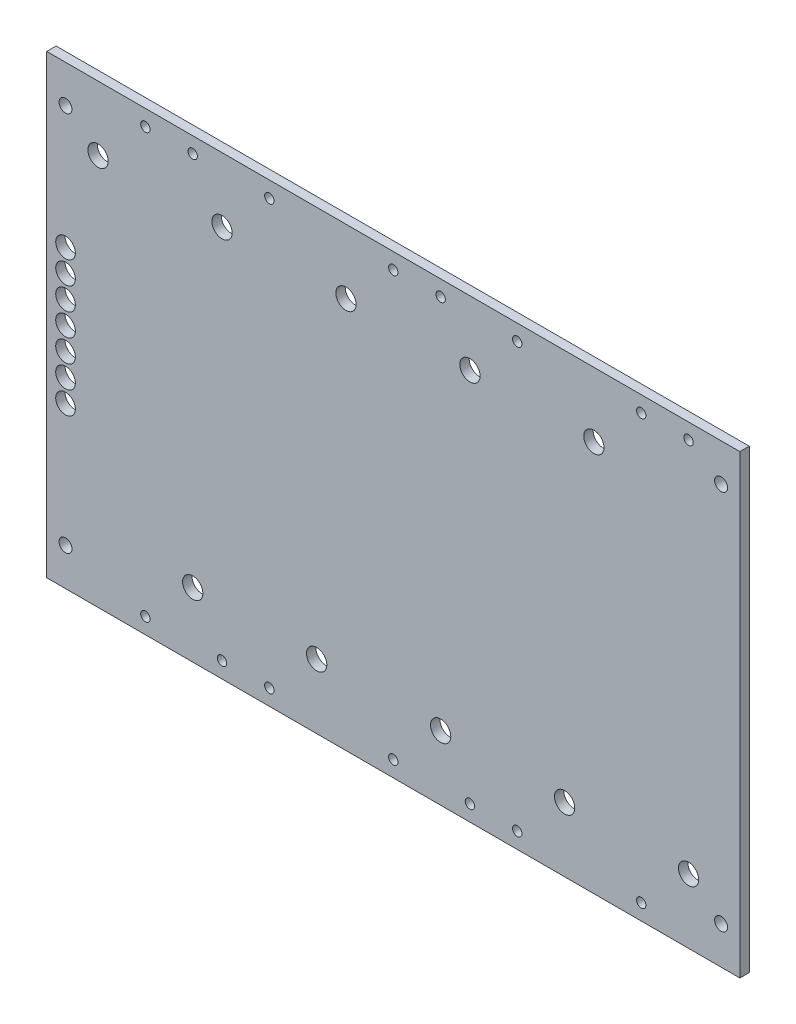
from build123d import *

# Parameters (mm, degrees)
SKETCH1_W           = 117.1702
SKETCH1_H           = 77.0636
SKETCH1_R           = 1.0922
SKETCH1_R_2         = 0.79375
SKETCH1_R_3         = 1.7145
SKETCH1_R_4         = 1.659299133
BOSS_EXTRUDE1_DEPTH = 1.5875


with BuildPart() as part:
    # Sketch1 → Boss-Extrude1 (new body)
    with BuildSketch(Plane.XY):
        with Locations((52.2351, 38.5318)):
            Rectangle(SKETCH1_W, SKETCH1_H)
        with Locations((-3.175, 6.35)):
            Circle(SKETCH1_R, mode=Mode.SUBTRACT)
        with Locations((10.3251, 2.6924)):
            Circle(SKETCH1_R_2, mode=Mode.SUBTRACT)
        with Locations((23.2791, 2.6924)):
            Circle(SKETCH1_R_2, mode=Mode.SUBTRACT)
        with Locations((18.3261, 10.9093)):
            Circle(SKETCH1_R_3, mode=Mode.SUBTRACT)
        with Locations((31.2801, 2.6924)):
            Circle(SKETCH1_R_2, mode=Mode.SUBTRACT)
        with Locations((52.2351, 2.6924)):
            Circle(SKETCH1_R_2, mode=Mode.SUBTRACT)
        with Locations((39.2811, 10.9093)):
            Circle(SKETCH1_R_3, mode=Mode.SUBTRACT)
        with Locations((-3.175, 27.1018)):
            Circle(SKETCH1_R_4, mode=Mode.SUBTRACT)
        with Locations((-3.175, 30.9118)):
            Circle(SKETCH1_R_4, mode=Mode.SUBTRACT)
        with Locations((-3.175, 34.7218)):
            Circle(SKETCH1_R_4, mode=Mode.SUBTRACT)
        with Locations((65.1891, 2.6924)):
            Circle(SKETCH1_R_2, mode=Mode.SUBTRACT)
        with Locations((73.1901, 2.6924)):
            Circle(SKETCH1_R_2, mode=Mode.SUBTRACT)
        with Locations((60.2361, 10.9093)):
            Circle(SKETCH1_R_3, mode=Mode.SUBTRACT)
        with Locations((81.1911, 10.9093)):
            Circle(SKETCH1_R_3, mode=Mode.SUBTRACT)
        with Locations((94.1451, 2.6924)):
            Circle(SKETCH1_R_2, mode=Mode.SUBTRACT)
        with Locations((107.6452, 6.35)):
            Circle(SKETCH1_R, mode=Mode.SUBTRACT)
        with Locations((102.1461, 10.9093)):
            Circle(SKETCH1_R_3, mode=Mode.SUBTRACT)
        with Locations((-3.175, 38.5318)):
            Circle(SKETCH1_R_4, mode=Mode.SUBTRACT)
        with Locations((-3.175, 42.3418)):
            Circle(SKETCH1_R_4, mode=Mode.SUBTRACT)
        with Locations((-3.175, 46.1518)):
            Circle(SKETCH1_R_4, mode=Mode.SUBTRACT)
        with Locations((-3.175, 49.9618)):
            Circle(SKETCH1_R_4, mode=Mode.SUBTRACT)
        with Locations((2.3241, 66.1543)):
            Circle(SKETCH1_R_3, mode=Mode.SUBTRACT)
        with Locations((23.2791, 66.1543)):
            Circle(SKETCH1_R_3, mode=Mode.SUBTRACT)
        with Locations((-3.175, 70.7136)):
            Circle(SKETCH1_R, mode=Mode.SUBTRACT)
        with Locations((10.3251, 74.3712)):
            Circle(SKETCH1_R_2, mode=Mode.SUBTRACT)
        with Locations((18.3261, 74.4347)):
            Circle(SKETCH1_R_2, mode=Mode.SUBTRACT)
        with Locations((44.2341, 66.1543)):
            Circle(SKETCH1_R_3, mode=Mode.SUBTRACT)
        with Locations((31.2801, 74.3712)):
            Circle(SKETCH1_R_2, mode=Mode.SUBTRACT)
        with Locations((52.2351, 74.3712)):
            Circle(SKETCH1_R_2, mode=Mode.SUBTRACT)
        with Locations((65.1891, 66.1543)):
            Circle(SKETCH1_R_3, mode=Mode.SUBTRACT)
        with Locations((86.1441, 66.1543)):
            Circle(SKETCH1_R_3, mode=Mode.SUBTRACT)
        with Locations((60.2361, 74.4347)):
            Circle(SKETCH1_R_2, mode=Mode.SUBTRACT)
        with Locations((73.1901, 74.3712)):
            Circle(SKETCH1_R_2, mode=Mode.SUBTRACT)
        with Locations((107.6452, 70.7136)):
            Circle(SKETCH1_R, mode=Mode.SUBTRACT)
        with Locations((94.1451, 74.3712)):
            Circle(SKETCH1_R_2, mode=Mode.SUBTRACT)
        with Locations((102.1461, 74.4347)):
            Circle(SKETCH1_R_2, mode=Mode.SUBTRACT)
    extrude(amount=BOSS_EXTRUDE1_DEPTH)


solid = part.part
